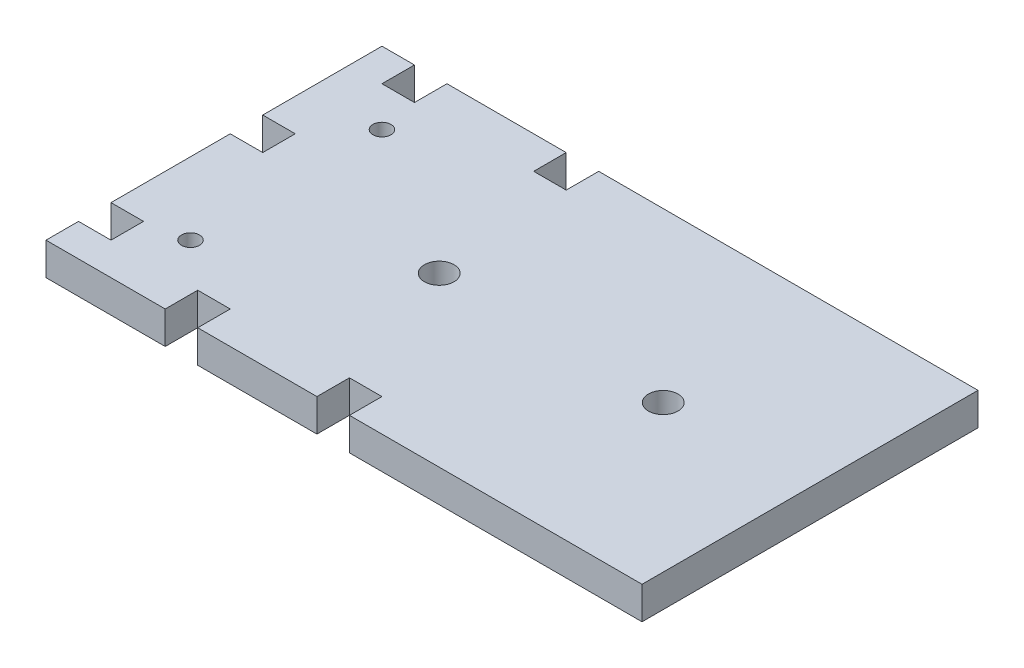
from build123d import *

# Parameters (mm, degrees)
SKETCH1_W           = 82.5
SKETCH1_H           = 46.5
SKETCH1_R           = 2.05
BOSS_EXTRUDE1_DEPTH = 4.5
SKETCH2_R           = 1.25
CUT_EXTRUDE1_DEPTH  = 5.5
SKETCH3_W           = 4.5
SKETCH3_H           = 4.5
CUT_EXTRUDE2_DEPTH  = 5.5


with BuildPart() as part:
    # Sketch1 → Boss-Extrude1 (new body)
    with BuildSketch(Plane(origin=(0, 0, 0), x_dir=(1, 0, 0), z_dir=(0, 1, 0))):
        Rectangle(SKETCH1_W, SKETCH1_H)
        with Locations((20.92918, 0)):
            Circle(SKETCH1_R, mode=Mode.SUBTRACT)
        with Locations((-10.07082, 0)):
            Circle(SKETCH1_R, mode=Mode.SUBTRACT)
    extrude(amount=BOSS_EXTRUDE1_DEPTH)

    # Sketch2 → Cut-Extrude1 (cut, through all)
    with BuildSketch(Plane(origin=(0, 4.5, 0), x_dir=(1, 0, 0), z_dir=(0, 1, 0))):
        with Locations((-31.25, -13.25)):
            Circle(SKETCH2_R)
        with Locations((-31.25, 13.25)):
            Circle(SKETCH2_R)
    extrude(amount=-CUT_EXTRUDE1_DEPTH, mode=Mode.SUBTRACT)

    # Sketch3 → Cut-Extrude2 (cut, through all)
    with BuildSketch(Plane(origin=(0, 0, 0), x_dir=(-1, 0, 0), z_dir=(0, -1, 0))):
        with Locations((34.5, 21)):
            Rectangle(SKETCH3_W, SKETCH3_H)
        with Locations((39, 4.5)):
            Rectangle(SKETCH3_W, SKETCH3_H)
        with Locations((39, -16.5)):
            Rectangle(SKETCH3_W, SKETCH3_H)
        with Locations((22.5, -21)):
            Rectangle(SKETCH3_W, SKETCH3_H)
        with Locations((1.5, -21)):
            Rectangle(SKETCH3_W, SKETCH3_H)
        with Locations((13.5, 21)):
            Rectangle(SKETCH3_W, SKETCH3_H)
    extrude(amount=-CUT_EXTRUDE2_DEPTH, mode=Mode.SUBTRACT)


solid = part.part
